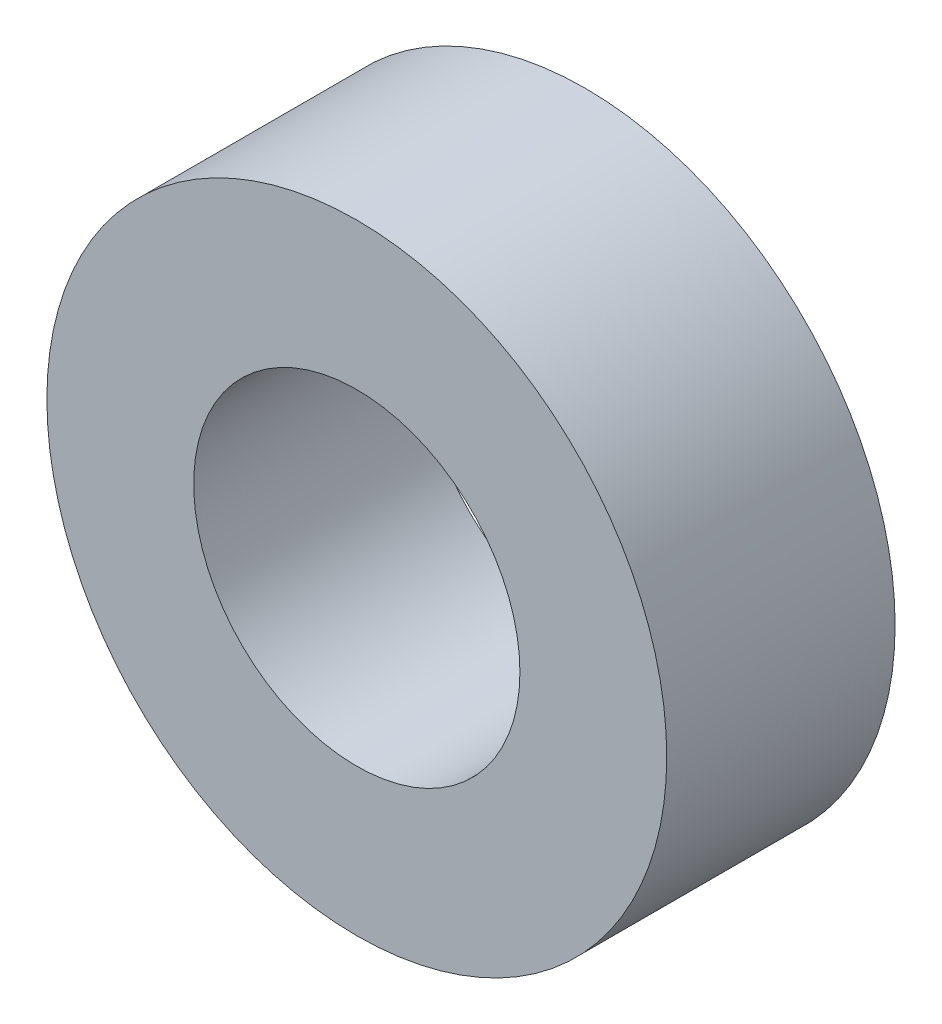
from build123d import *

# Parameters (mm, degrees)
ESQUISSE1_R      = 9.5
ESQUISSE1_R_2    = 5
EXTRUSION1_DEPTH = 7


with BuildPart() as part:
    # Esquisse1 → Extrusion1 (new body)
    with BuildSketch(Plane.XY):
        Circle(ESQUISSE1_R)
        Circle(ESQUISSE1_R_2, mode=Mode.SUBTRACT)
    extrude(amount=EXTRUSION1_DEPTH)


solid = part.part
